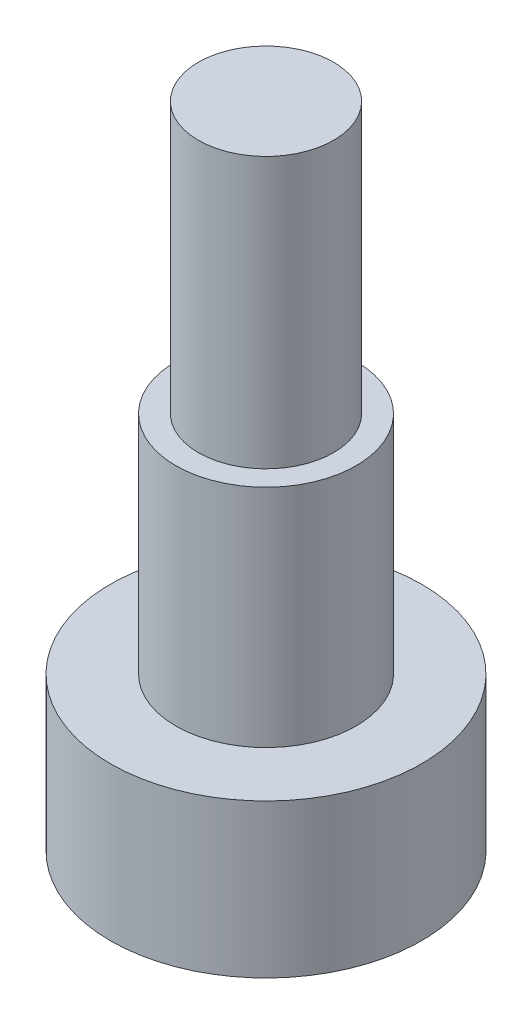
from build123d import *

# Parameters (mm, degrees)
SKETCH_1_R      = 3.45
EXTRUDE_1_DEPTH = 3.4
SKETCH_2_R      = 2
EXTRUDE_2_DEPTH = 5
SKETCH_3_R      = 1.5
EXTRUDE_3_DEPTH = 6


with BuildPart() as part:
    # 草图1 → 凸台-拉伸1 (new body)
    with BuildSketch(Plane(origin=(0, 0, 0), x_dir=(1, 0, 0), z_dir=(0, 1, 0))):
        Circle(SKETCH_1_R)
    extrude(amount=EXTRUDE_1_DEPTH)

    # 草图2 → 凸台-拉伸2 (add)
    with BuildSketch(Plane(origin=(0, 3.4, 0), x_dir=(1, 0, 0), z_dir=(0, 1, 0))):
        Circle(SKETCH_2_R)
    extrude(amount=EXTRUDE_2_DEPTH)

    # 草图3 → 凸台-拉伸3 (add)
    with BuildSketch(Plane(origin=(0, 8.4, 0), x_dir=(1, 0, 0), z_dir=(0, 1, 0))):
        Circle(SKETCH_3_R)
    extrude(amount=EXTRUDE_3_DEPTH)


solid = part.part
